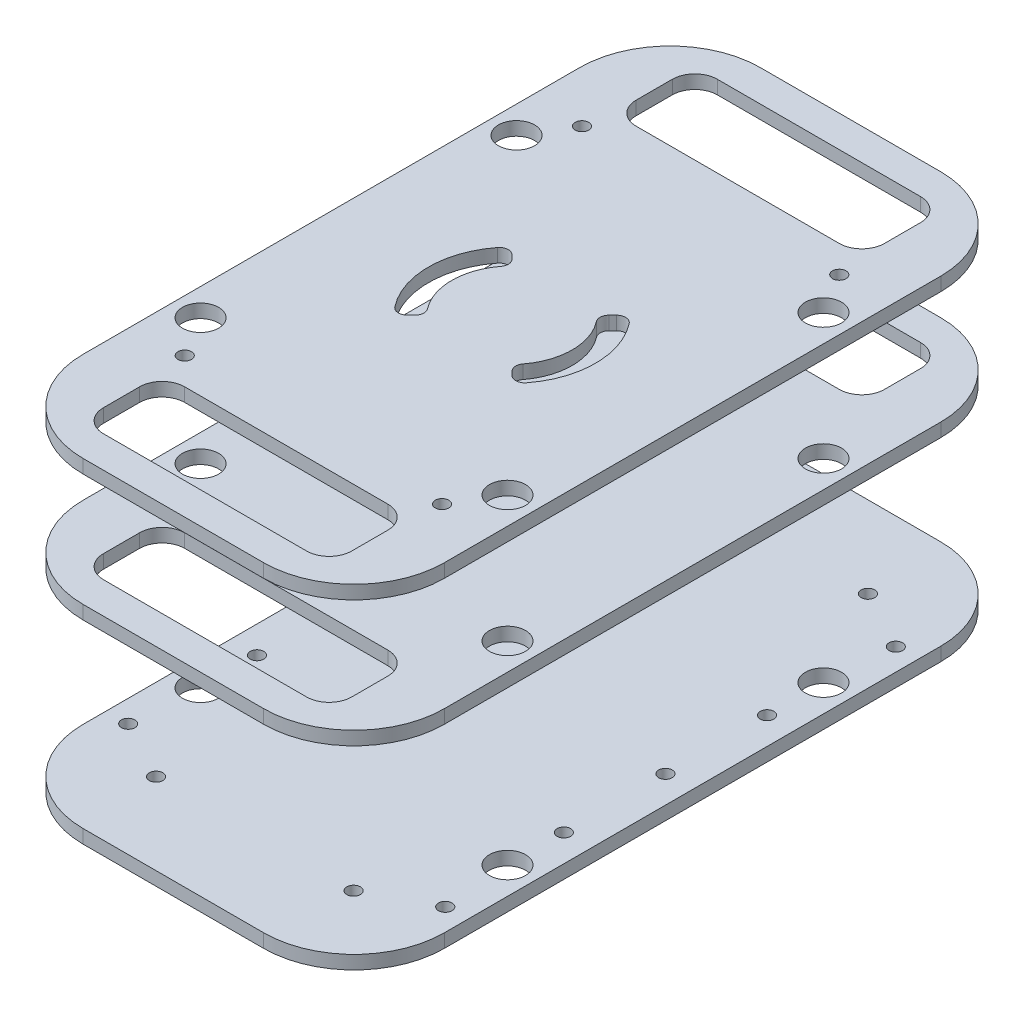
from build123d import *

# Parameters (mm, degrees)
SKETCH1_R           = 4
SKETCH1_R_2         = 1.5
BOSS_EXTRUDE1_DEPTH = 3
BOSS_EXTRUDE2_START = 43
SKETCH1_2_R         = 1.5
SKETCH1_2_R_2       = 4
BOSS_EXTRUDE2_DEPTH = 3
BOSS_EXTRUDE3_START = 71
SKETCH1_3_R         = 1.5
SKETCH1_3_R_2       = 4
BOSS_EXTRUDE3_DEPTH = 3
SKETCH3_R           = 1.5
CUT_EXTRUDE1_DEPTH  = 10
CUT_EXTRUDE2_DEPTH  = 31
CUT_EXTRUDE3_DEPTH  = 10
SKETCH6_R           = 1.5
CUT_EXTRUDE5_DEPTH  = 31


with BuildPart() as part:
    # Sketch1 → Boss-Extrude1 (new body)
    with BuildSketch(Plane(origin=(0, 0, 0), x_dir=(1, 0, 0), z_dir=(0, 1, 0))):
        with BuildLine():
            Line((-20, -75), (20, -75))
            ThreePointArc((20, -75), (34.142135624, -69.142135624), (40, -55))
            Line((40, -55), (40, 55))
            ThreePointArc((40, 55), (34.142135624, 69.142135624), (20, 75))
            Line((20, 75), (-20, 75))
            ThreePointArc((-20, 75), (-34.142135624, 69.142135624), (-40, 55))
            Line((-40, 55), (-40, -55))
            ThreePointArc((-40, -55), (-34.142135624, -69.142135624), (-20, -75))
        make_face()
        with Locations((-34, 35)):
            Circle(SKETCH1_R, mode=Mode.SUBTRACT)
        with Locations((34, 35)):
            Circle(SKETCH1_R, mode=Mode.SUBTRACT)
        with Locations((34, -35)):
            Circle(SKETCH1_R, mode=Mode.SUBTRACT)
        with Locations((-34, -35)):
            Circle(SKETCH1_R, mode=Mode.SUBTRACT)
        with Locations((21.882352941, -56.966911765)):
            Circle(SKETCH1_R_2, mode=Mode.SUBTRACT)
        with Locations((35.117647059, -49.908088235)):
            Circle(SKETCH1_R_2, mode=Mode.SUBTRACT)
        with Locations((-35.117647059, 49.908088235)):
            Circle(SKETCH1_R_2, mode=Mode.SUBTRACT)
        with Locations((-21.882352941, 56.966911765)):
            Circle(SKETCH1_R_2, mode=Mode.SUBTRACT)
        with Locations((35.117647059, 49.908088235)):
            Circle(SKETCH1_R_2, mode=Mode.SUBTRACT)
        with Locations((21.882352941, 56.966911765)):
            Circle(SKETCH1_R_2, mode=Mode.SUBTRACT)
        with Locations((-21.882352941, -56.966911765)):
            Circle(SKETCH1_R_2, mode=Mode.SUBTRACT)
        with Locations((-35.117647059, -49.908088235)):
            Circle(SKETCH1_R_2, mode=Mode.SUBTRACT)
    extrude(amount=BOSS_EXTRUDE1_DEPTH)

    # Sketch6 → Cut-Extrude5 (cut)
    with BuildSketch(Plane(origin=(0, 3, 0), x_dir=(1, 0, 0), z_dir=(0, 1, 0))):
        with Locations((-34, 22.5)):
            Circle(SKETCH6_R)
        with Locations((-34, -22.5)):
            Circle(SKETCH6_R)
        with Locations((-34, 0)):
            Circle(SKETCH6_R)
        with Locations((34, -22.5)):
            Circle(SKETCH6_R)
        with Locations((34, 0)):
            Circle(SKETCH6_R)
        with Locations((34, 22.5)):
            Circle(SKETCH6_R)
    extrude(amount=-CUT_EXTRUDE5_DEPTH, mode=Mode.SUBTRACT)


with BuildPart() as body_2:
    # Sketch1_2 → Boss-Extrude2 (new body)
    with BuildSketch(Plane(origin=(0, 0, 0), x_dir=(1, 0, 0), z_dir=(0, 1, 0)).offset(BOSS_EXTRUDE2_START)):
        with BuildLine():
            ThreePointArc((-20, -75), (-34.142135624, -69.142135624), (-40, -55))
            Line((-40, -55), (-40, 55))
            ThreePointArc((-40, 55), (-34.142135624, 69.142135624), (-20, 75))
            Line((-20, 75), (20, 75))
            ThreePointArc((20, 75), (34.142135624, 69.142135624), (40, 55))
            Line((40, 55), (40, -55))
            ThreePointArc((40, -55), (34.142135624, -69.142135624), (20, -75))
            Line((20, -75), (-20, -75))
        make_face()
        with Locations((35.117647059, -49.908088235)):
            Circle(SKETCH1_2_R, mode=Mode.SUBTRACT)
        with Locations((21.882352941, -56.966911765)):
            Circle(SKETCH1_2_R, mode=Mode.SUBTRACT)
        with Locations((34, 35)):
            Circle(SKETCH1_2_R_2, mode=Mode.SUBTRACT)
        with Locations((-34, 35)):
            Circle(SKETCH1_2_R_2, mode=Mode.SUBTRACT)
        with Locations((34, -35)):
            Circle(SKETCH1_2_R_2, mode=Mode.SUBTRACT)
        with Locations((-34, -35)):
            Circle(SKETCH1_2_R_2, mode=Mode.SUBTRACT)
        with Locations((35.117647059, -49.908088235)):
            Circle(SKETCH1_2_R)
        with Locations((-21.882352941, -56.966911765)):
            Circle(SKETCH1_2_R)
        with Locations((-35.117647059, -49.908088235)):
            Circle(SKETCH1_2_R)
        with Locations((21.882352941, -56.966911765)):
            Circle(SKETCH1_2_R)
        with Locations((-21.882352941, 56.966911765)):
            Circle(SKETCH1_2_R)
        with Locations((-35.117647059, 49.908088235)):
            Circle(SKETCH1_2_R)
        with Locations((21.882352941, 56.966911765)):
            Circle(SKETCH1_2_R)
        with Locations((35.117647059, 49.908088235)):
            Circle(SKETCH1_2_R)
    extrude(amount=BOSS_EXTRUDE2_DEPTH)

    # Sketch5 → Cut-Extrude3 (cut)
    with BuildSketch(Plane(origin=(0, 46, 0), x_dir=(1, 0, 0), z_dir=(0, 1, 0))):
        with BuildLine():
            ThreePointArc((-22.5, 50.004885749), (-26.035533906, 51.469351843), (-27.5, 55.004885749))
            Line((-27.5, 55.004885749), (-27.5, 63.004885749))
            ThreePointArc((-27.5, 63.004885749), (-26.035533906, 66.540419655), (-22.5, 68.004885749))
            Line((-22.5, 68.004885749), (22.5, 68.004885749))
            ThreePointArc((22.5, 68.004885749), (26.035533906, 66.540419655), (27.5, 63.004885749))
            Line((27.5, 63.004885749), (27.5, 55.004885749))
            ThreePointArc((27.5, 55.004885749), (26.035533906, 51.469351843), (22.5, 50.004885749))
            Line((22.5, 50.004885749), (-22.5, 50.004885749))
        make_face()
        with BuildLine():
            Line((-22.5, -68.004885749), (22.5, -68.004885749))
            ThreePointArc((22.5, -68.004885749), (26.035533906, -66.540419655), (27.5, -63.004885749))
            Line((27.5, -63.004885749), (27.5, -55.004885749))
            ThreePointArc((27.5, -55.004885749), (26.035533906, -51.469351843), (22.5, -50.004885749))
            Line((22.5, -50.004885749), (-22.5, -50.004885749))
            ThreePointArc((-22.5, -50.004885749), (-26.035533906, -51.469351843), (-27.5, -55.004885749))
            Line((-27.5, -55.004885749), (-27.5, -63.004885749))
            ThreePointArc((-27.5, -63.004885749), (-26.035533906, -66.540419655), (-22.5, -68.004885749))
        make_face()
    extrude(amount=-CUT_EXTRUDE3_DEPTH, mode=Mode.SUBTRACT)


with BuildPart() as body_3:
    # Sketch1_3 → Boss-Extrude3 (new body)
    with BuildSketch(Plane(origin=(0, 0, 0), x_dir=(1, 0, 0), z_dir=(0, 1, 0)).offset(BOSS_EXTRUDE3_START)):
        with BuildLine():
            ThreePointArc((-20, -75), (-34.142135624, -69.142135624), (-40, -55))
            Line((-40, -55), (-40, 55))
            ThreePointArc((-40, 55), (-34.142135624, 69.142135624), (-20, 75))
            Line((-20, 75), (20, 75))
            ThreePointArc((20, 75), (34.142135624, 69.142135624), (40, 55))
            Line((40, 55), (40, -55))
            ThreePointArc((40, -55), (34.142135624, -69.142135624), (20, -75))
            Line((20, -75), (-20, -75))
        make_face()
        with Locations((-21.882352941, -56.966911765)):
            Circle(SKETCH1_3_R, mode=Mode.SUBTRACT)
        with Locations((21.882352941, 56.966911765)):
            Circle(SKETCH1_3_R, mode=Mode.SUBTRACT)
        with Locations((35.117647059, 49.908088235)):
            Circle(SKETCH1_3_R, mode=Mode.SUBTRACT)
        with Locations((-35.117647059, 49.908088235)):
            Circle(SKETCH1_3_R, mode=Mode.SUBTRACT)
        with Locations((35.117647059, -49.908088235)):
            Circle(SKETCH1_3_R, mode=Mode.SUBTRACT)
        with Locations((21.882352941, -56.966911765)):
            Circle(SKETCH1_3_R, mode=Mode.SUBTRACT)
        with Locations((34, 35)):
            Circle(SKETCH1_3_R_2, mode=Mode.SUBTRACT)
        with Locations((-34, 35)):
            Circle(SKETCH1_3_R_2, mode=Mode.SUBTRACT)
        with Locations((34, -35)):
            Circle(SKETCH1_3_R_2, mode=Mode.SUBTRACT)
        with Locations((-34, -35)):
            Circle(SKETCH1_3_R_2, mode=Mode.SUBTRACT)
        with Locations((-21.882352941, 56.966911765)):
            Circle(SKETCH1_3_R, mode=Mode.SUBTRACT)
        with Locations((-35.117647059, -49.908088235)):
            Circle(SKETCH1_3_R, mode=Mode.SUBTRACT)
        with Locations((-21.882352941, 56.966911765)):
            Circle(SKETCH1_3_R)
        with Locations((-35.117647059, 49.908088235)):
            Circle(SKETCH1_3_R)
        with Locations((21.882352941, 56.966911765)):
            Circle(SKETCH1_3_R)
        with Locations((35.117647059, 49.908088235)):
            Circle(SKETCH1_3_R)
        with Locations((35.117647059, -49.908088235)):
            Circle(SKETCH1_3_R)
        with Locations((21.882352941, -56.966911765)):
            Circle(SKETCH1_3_R)
        with Locations((-35.117647059, -49.908088235)):
            Circle(SKETCH1_3_R)
        with Locations((-21.882352941, -56.966911765)):
            Circle(SKETCH1_3_R)
    extrude(amount=BOSS_EXTRUDE3_DEPTH)

    # Sketch3 → Cut-Extrude1 (cut)
    with BuildSketch(Plane(origin=(0, 74, 0), x_dir=(1, 0, 0), z_dir=(0, 1, 0))):
        with Locations((28.5, 44)):
            Circle(SKETCH3_R)
        with Locations((-28.5, 44)):
            Circle(SKETCH3_R)
        with Locations((-28.5, -44)):
            Circle(SKETCH3_R)
        with Locations((28.5, -44)):
            Circle(SKETCH3_R)
    extrude(amount=-CUT_EXTRUDE1_DEPTH, mode=Mode.SUBTRACT)

    # Sketch4 → Cut-Extrude2 (cut)
    with BuildSketch(Plane(origin=(0, 74, 0), x_dir=(1, 0, 0), z_dir=(0, 1, 0))):
        with BuildLine():
            ThreePointArc((22.5, 68.004885749), (26.035533906, 66.540419655), (27.5, 63.004885749))
            Line((27.5, 63.004885749), (27.5, 55.004885749))
            ThreePointArc((27.5, 55.004885749), (26.035533906, 51.469351843), (22.5, 50.004885749))
            Line((22.5, 50.004885749), (-22.5, 50.004885749))
            ThreePointArc((-22.5, 50.004885749), (-26.035533906, 51.469351843), (-27.5, 55.004885749))
            Line((-27.5, 55.004885749), (-27.5, 63.004885749))
            ThreePointArc((-27.5, 63.004885749), (-26.035533906, 66.540419655), (-22.5, 68.004885749))
            Line((-22.5, 68.004885749), (22.5, 68.004885749))
        make_face()
        with BuildLine():
            ThreePointArc((-27.5, -55.004885749), (-26.035533906, -51.469351843), (-22.5, -50.004885749))
            Line((-22.5, -50.004885749), (22.5, -50.004885749))
            ThreePointArc((22.5, -50.004885749), (26.035533906, -51.469351843), (27.5, -55.004885749))
            Line((27.5, -55.004885749), (27.5, -63.004885749))
            ThreePointArc((27.5, -63.004885749), (26.035533906, -66.540419655), (22.5, -68.004885749))
            Line((22.5, -68.004885749), (-22.5, -68.004885749))
            ThreePointArc((-22.5, -68.004885749), (-26.035533906, -66.540419655), (-27.5, -63.004885749))
            Line((-27.5, -63.004885749), (-27.5, -55.004885749))
        make_face()
        with BuildLine():
            Line((11.576890024, 11.576890024), (10.7586633, 10.7586633))
            ThreePointArc((10.7586633, 10.7586633), (10.177145932, 9.475056209), (10.586413981, 8.126609221))
            ThreePointArc((10.586413981, 8.126609221), (13.345933404, 0), (10.586413981, -8.126609221))
            ThreePointArc((10.586413981, -8.126609221), (10.177145932, -9.475056209), (10.7586633, -10.7586633))
            Line((10.7586633, -10.7586633), (11.576890024, -11.576890024))
            ThreePointArc((11.576890024, -11.576890024), (13.112584835, -12.158983629), (14.566365097, -11.394971545))
            ThreePointArc((14.566365097, -11.394971545), (18.49390085, 0), (14.566365097, 11.394971545))
            ThreePointArc((14.566365097, 11.394971545), (13.112584835, 12.158983629), (11.576890024, 11.576890024))
        make_face()
        with BuildLine():
            ThreePointArc((-10.7586633, 10.7586633), (-10.177145932, 9.475056209), (-10.586413981, 8.126609221))
            ThreePointArc((-10.586413981, 8.126609221), (-13.345933404, 0), (-10.586413981, -8.126609221))
            ThreePointArc((-10.586413981, -8.126609221), (-10.177145932, -9.475056209), (-10.7586633, -10.7586633))
            Line((-10.7586633, -10.7586633), (-11.576890024, -11.576890024))
            ThreePointArc((-11.576890024, -11.576890024), (-13.112584835, -12.158983629), (-14.566365097, -11.394971545))
            ThreePointArc((-14.566365097, -11.394971545), (-18.49390085, 0), (-14.566365097, 11.394971545))
            ThreePointArc((-14.566365097, 11.394971545), (-13.112584835, 12.158983629), (-11.576890024, 11.576890024))
            Line((-11.576890024, 11.576890024), (-10.7586633, 10.7586633))
        make_face()
    extrude(amount=-CUT_EXTRUDE2_DEPTH, mode=Mode.SUBTRACT)


solid = Compound([part.part, body_2.part, body_3.part])
